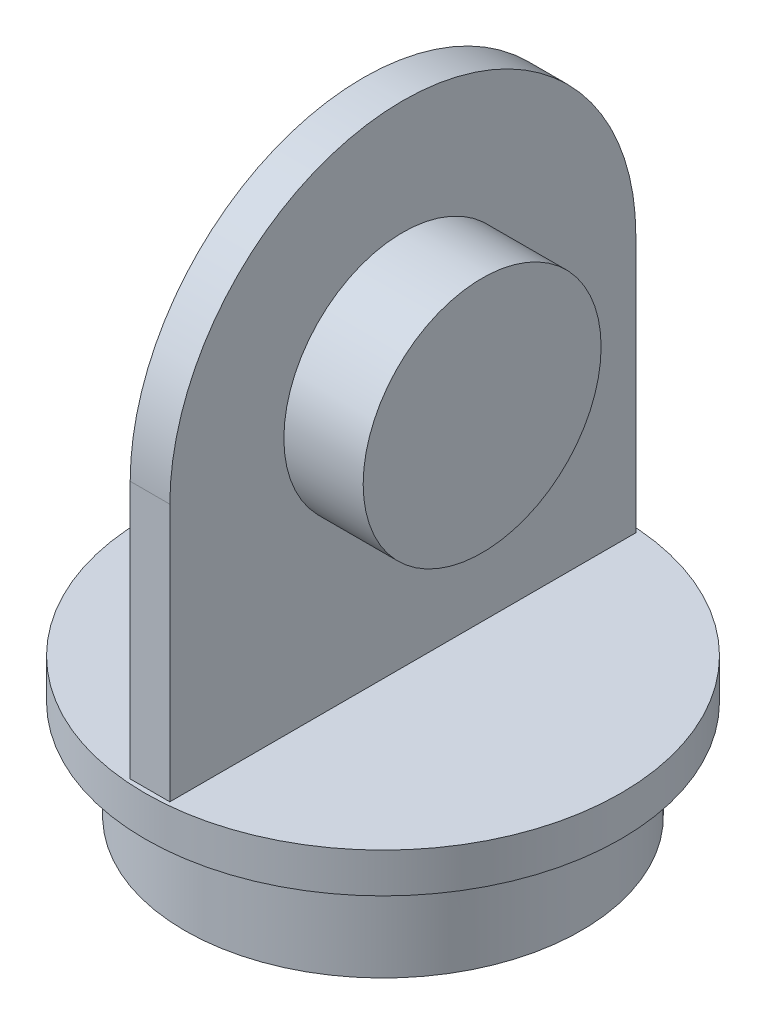
from build123d import *

# Parameters (mm, degrees)
SKETCH1_R           = 12
BOSS_EXTRUDE1_DEPTH = 2
BOSS_EXTRUDE2_DEPTH = 1
SKETCH3_R           = 10
BOSS_EXTRUDE3_DEPTH = 5
SKETCH4_R           = 6
BOSS_EXTRUDE4_DEPTH = 5
SCALE1_SCALE        = 2


with BuildPart() as part:
    # Sketch1 → Boss-Extrude1 (new body)
    with BuildSketch(Plane(origin=(0, 0, 0), x_dir=(1, 0, 0), z_dir=(0, 1, 0))):
        Circle(SKETCH1_R)
    extrude(amount=BOSS_EXTRUDE1_DEPTH)

    # Sketch2 → Boss-Extrude2 (add, symmetric)
    with BuildSketch(Plane(origin=(0, 0, 0), x_dir=(0, 0, -1), z_dir=(1, 0, 0))):
        with BuildLine():
            Line((-11.75, 2), (-11.75, 15))
            ThreePointArc((-11.75, 15), (0, 26.75), (11.75, 15))
            Line((11.75, 15), (11.75, 2))
            Line((11.75, 2), (-11.75, 2))
        make_face()
    extrude(amount=BOSS_EXTRUDE2_DEPTH, both=True)

    # Sketch3 → Boss-Extrude3 (add)
    with BuildSketch(Plane.XZ):
        Circle(SKETCH3_R)
    extrude(amount=BOSS_EXTRUDE3_DEPTH)

    # Sketch4 → Boss-Extrude4 (add, symmetric)
    with BuildSketch(Plane(origin=(0, 0, 0), x_dir=(0, 0, -1), z_dir=(1, 0, 0))):
        with Locations((0, 15)):
            Circle(SKETCH4_R)
    extrude(amount=BOSS_EXTRUDE4_DEPTH, both=True)


with BuildPart() as part_1:
    # Scale1: scaled about (0, 5.516721754, 0)
    add(part.part.scale(SCALE1_SCALE).moved(Location((0, -5.516721754, 0))))


solid = part_1.part
